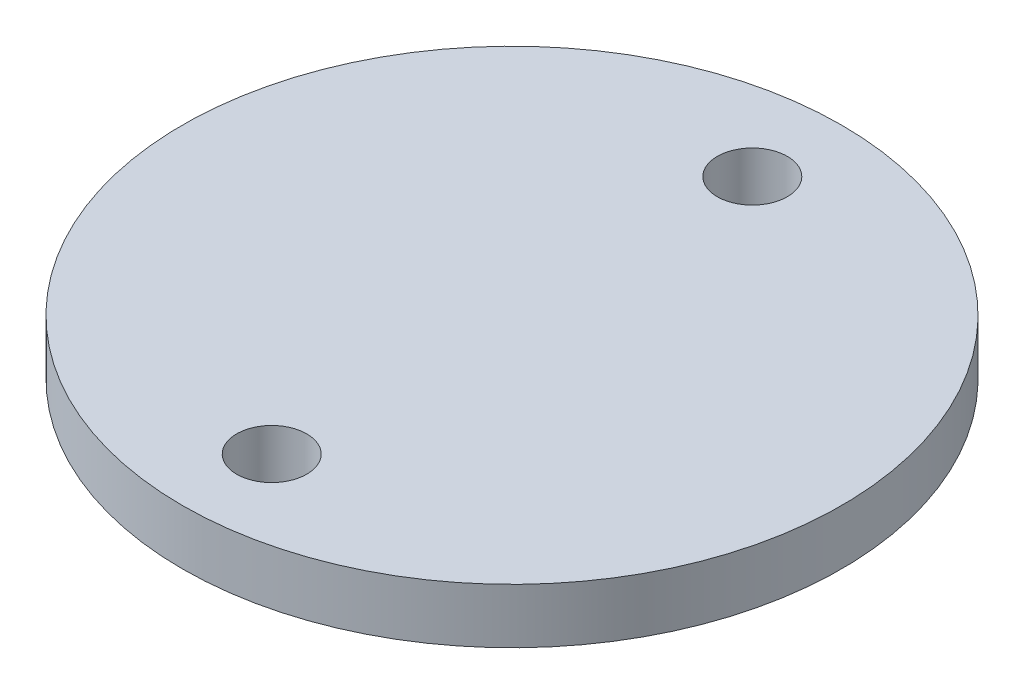
from build123d import *

# Parameters (mm, degrees)
SKETCH1_R           = 30.48
BOSS_EXTRUDE1_DEPTH = 5.08
SKETCH2_R           = 3.2385
CUT_EXTRUDE1_DEPTH  = 6.08


with BuildPart() as part:
    # Sketch1 → Boss-Extrude1 (new body)
    with BuildSketch(Plane(origin=(0, 0, 0), x_dir=(1, 0, 0), z_dir=(0, 1, 0))):
        Circle(SKETCH1_R)
    extrude(amount=BOSS_EXTRUDE1_DEPTH)

    # Sketch2 → Cut-Extrude1 (cut, through all)
    with BuildSketch(Plane(origin=(0, 5.08, 0), x_dir=(1, 0, 0), z_dir=(0, 1, 0))):
        with Locations((0, 22.225)):
            Circle(SKETCH2_R)
        with Locations((0, -22.225)):
            Circle(SKETCH2_R)
    extrude(amount=-CUT_EXTRUDE1_DEPTH, mode=Mode.SUBTRACT)


solid = part.part
